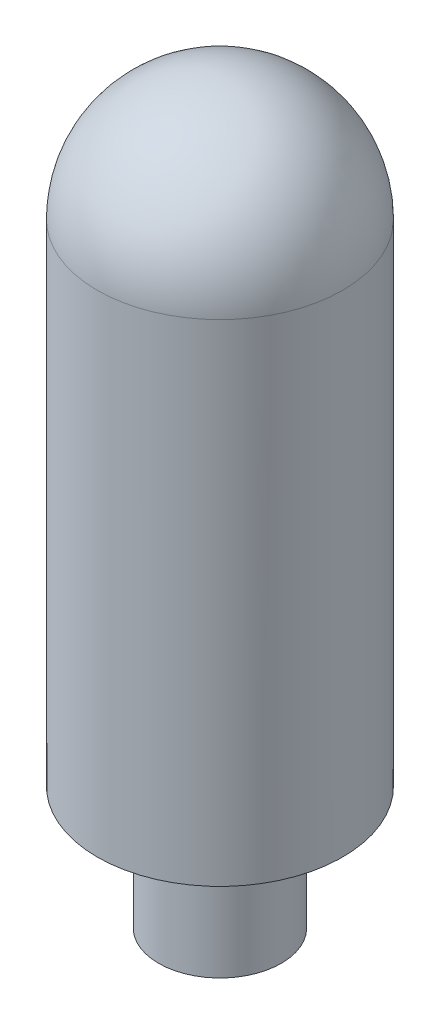
from build123d import *


with BuildPart() as part:
    # Sketch2 → Revolve1 (revolve)
    with BuildSketch(Plane.XY):
        with BuildLine():
            Line((0, 0), (2, 0))
            Line((2, 0), (2, 4))
            Line((2, 4), (4, 4))
            Line((4, 4), (4, 20))
            ThreePointArc((4, 20), (2.828427125, 22.828427125), (0, 24))
            Line((0, 24), (0, 0))
        make_face()
    revolve(axis=Axis((0, 34.293540803, 0), (0, -1, 0)))


solid = part.part
